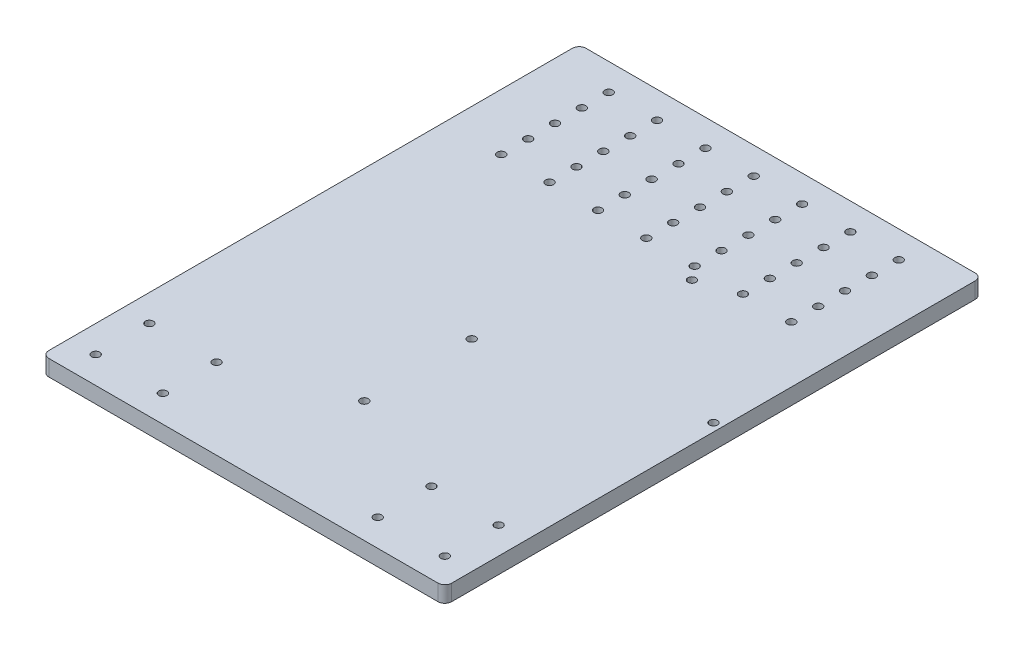
from build123d import *

# Parameters (mm, degrees)
SKETCH1_R           = 1.5
BOSS_EXTRUDE1_DEPTH = 6


with BuildPart() as part:
    # Sketch1 → Boss-Extrude1 (new body)
    with BuildSketch(Plane(origin=(0, 0, 0), x_dir=(1, 0, 0), z_dir=(0, 1, 0))):
        with BuildLine():
            Line((2.54, 0), (147.46, 0))
            ThreePointArc((147.46, 0), (149.256051224, 0.743948776), (150, 2.54))
            Line((150, 2.54), (150, 197.46))
            ThreePointArc((150, 197.46), (149.256051224, 199.256051224), (147.46, 200))
            Line((147.46, 200), (2.54, 200))
            ThreePointArc((2.54, 200), (0.743948776, 199.256051224), (0, 197.46))
            Line((0, 197.46), (0, 2.54))
            ThreePointArc((0, 2.54), (0.743948776, 0.743948776), (2.54, 0))
        make_face()
        with Locations((10, 30)):
            Circle(SKETCH1_R, mode=Mode.SUBTRACT)
        with Locations((35, 30)):
            Circle(SKETCH1_R, mode=Mode.SUBTRACT)
        with Locations((35, 10)):
            Circle(SKETCH1_R, mode=Mode.SUBTRACT)
        with Locations((10, 10)):
            Circle(SKETCH1_R, mode=Mode.SUBTRACT)
        with Locations((140, 10)):
            Circle(SKETCH1_R, mode=Mode.SUBTRACT)
        with Locations((115, 10)):
            Circle(SKETCH1_R, mode=Mode.SUBTRACT)
        with Locations((115, 30)):
            Circle(SKETCH1_R, mode=Mode.SUBTRACT)
        with Locations((140, 30)):
            Circle(SKETCH1_R, mode=Mode.SUBTRACT)
        with Locations((75, 150)):
            Circle(SKETCH1_R, mode=Mode.SUBTRACT)
        with Locations((39, 150)):
            Circle(SKETCH1_R, mode=Mode.SUBTRACT)
        with Locations((21, 150)):
            Circle(SKETCH1_R, mode=Mode.SUBTRACT)
        with Locations((57, 150)):
            Circle(SKETCH1_R, mode=Mode.SUBTRACT)
        with Locations((93, 150)):
            Circle(SKETCH1_R, mode=Mode.SUBTRACT)
        with Locations((111, 150)):
            Circle(SKETCH1_R, mode=Mode.SUBTRACT)
        with Locations((129, 150)):
            Circle(SKETCH1_R, mode=Mode.SUBTRACT)
        with Locations((129, 160)):
            Circle(SKETCH1_R, mode=Mode.SUBTRACT)
        with Locations((111, 160)):
            Circle(SKETCH1_R, mode=Mode.SUBTRACT)
        with Locations((93, 160)):
            Circle(SKETCH1_R, mode=Mode.SUBTRACT)
        with Locations((75, 160)):
            Circle(SKETCH1_R, mode=Mode.SUBTRACT)
        with Locations((57, 160)):
            Circle(SKETCH1_R, mode=Mode.SUBTRACT)
        with Locations((39, 160)):
            Circle(SKETCH1_R, mode=Mode.SUBTRACT)
        with Locations((21, 160)):
            Circle(SKETCH1_R, mode=Mode.SUBTRACT)
        with Locations((129, 170)):
            Circle(SKETCH1_R, mode=Mode.SUBTRACT)
        with Locations((111, 170)):
            Circle(SKETCH1_R, mode=Mode.SUBTRACT)
        with Locations((93, 170)):
            Circle(SKETCH1_R, mode=Mode.SUBTRACT)
        with Locations((75, 170)):
            Circle(SKETCH1_R, mode=Mode.SUBTRACT)
        with Locations((57, 170)):
            Circle(SKETCH1_R, mode=Mode.SUBTRACT)
        with Locations((39, 170)):
            Circle(SKETCH1_R, mode=Mode.SUBTRACT)
        with Locations((21, 170)):
            Circle(SKETCH1_R, mode=Mode.SUBTRACT)
        with Locations((129, 180)):
            Circle(SKETCH1_R, mode=Mode.SUBTRACT)
        with Locations((111, 180)):
            Circle(SKETCH1_R, mode=Mode.SUBTRACT)
        with Locations((93, 180)):
            Circle(SKETCH1_R, mode=Mode.SUBTRACT)
        with Locations((75, 180)):
            Circle(SKETCH1_R, mode=Mode.SUBTRACT)
        with Locations((57, 180)):
            Circle(SKETCH1_R, mode=Mode.SUBTRACT)
        with Locations((39, 180)):
            Circle(SKETCH1_R, mode=Mode.SUBTRACT)
        with Locations((21, 180)):
            Circle(SKETCH1_R, mode=Mode.SUBTRACT)
        with Locations((129, 190)):
            Circle(SKETCH1_R, mode=Mode.SUBTRACT)
        with Locations((111, 190)):
            Circle(SKETCH1_R, mode=Mode.SUBTRACT)
        with Locations((93, 190)):
            Circle(SKETCH1_R, mode=Mode.SUBTRACT)
        with Locations((75, 190)):
            Circle(SKETCH1_R, mode=Mode.SUBTRACT)
        with Locations((57, 190)):
            Circle(SKETCH1_R, mode=Mode.SUBTRACT)
        with Locations((39, 190)):
            Circle(SKETCH1_R, mode=Mode.SUBTRACT)
        with Locations((21, 190)):
            Circle(SKETCH1_R, mode=Mode.SUBTRACT)
        with Locations((75, 45)):
            Circle(SKETCH1_R, mode=Mode.SUBTRACT)
        with Locations((75, 85)):
            Circle(SKETCH1_R, mode=Mode.SUBTRACT)
        with Locations((147, 103)):
            Circle(SKETCH1_R, mode=Mode.SUBTRACT)
        with Locations((97, 145)):
            Circle(SKETCH1_R, mode=Mode.SUBTRACT)
    extrude(amount=BOSS_EXTRUDE1_DEPTH)


solid = part.part
